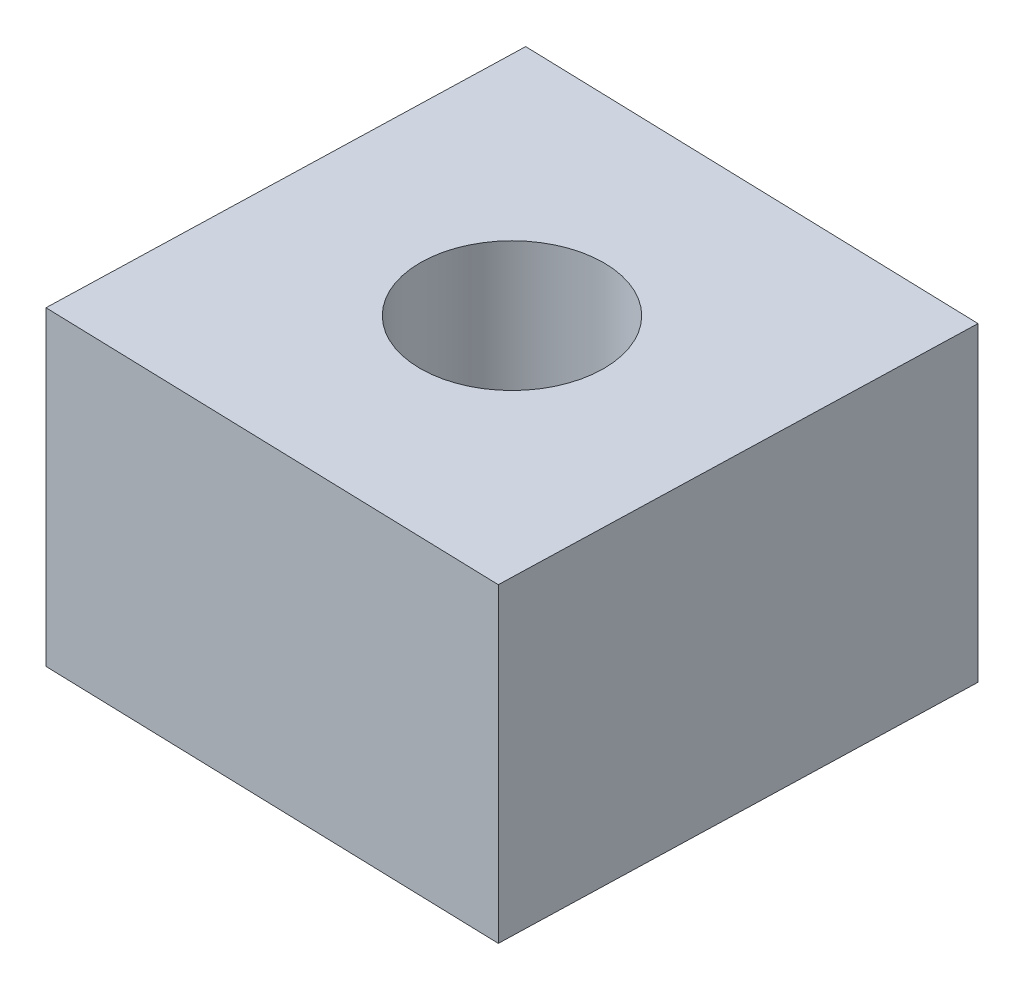
from build123d import *

# Parameters (mm, degrees)
SKETCH1_R           = 1.5
BOSS_EXTRUDE1_DEPTH = 5.08


with BuildPart() as part:
    # Sketch1 → Boss-Extrude1 (new body)
    with BuildSketch(Plane(origin=(0, 0, 0), x_dir=(1, 0, 0), z_dir=(0, 1, 0))):
        Polygon((-3.922137091, -3.697862909), (3.697862909, -3.922137091), (3.922137091, 3.697862909), (-3.697862909, 3.922137091), align=None)
        Circle(SKETCH1_R, mode=Mode.SUBTRACT)
    extrude(amount=BOSS_EXTRUDE1_DEPTH)


solid = part.part
